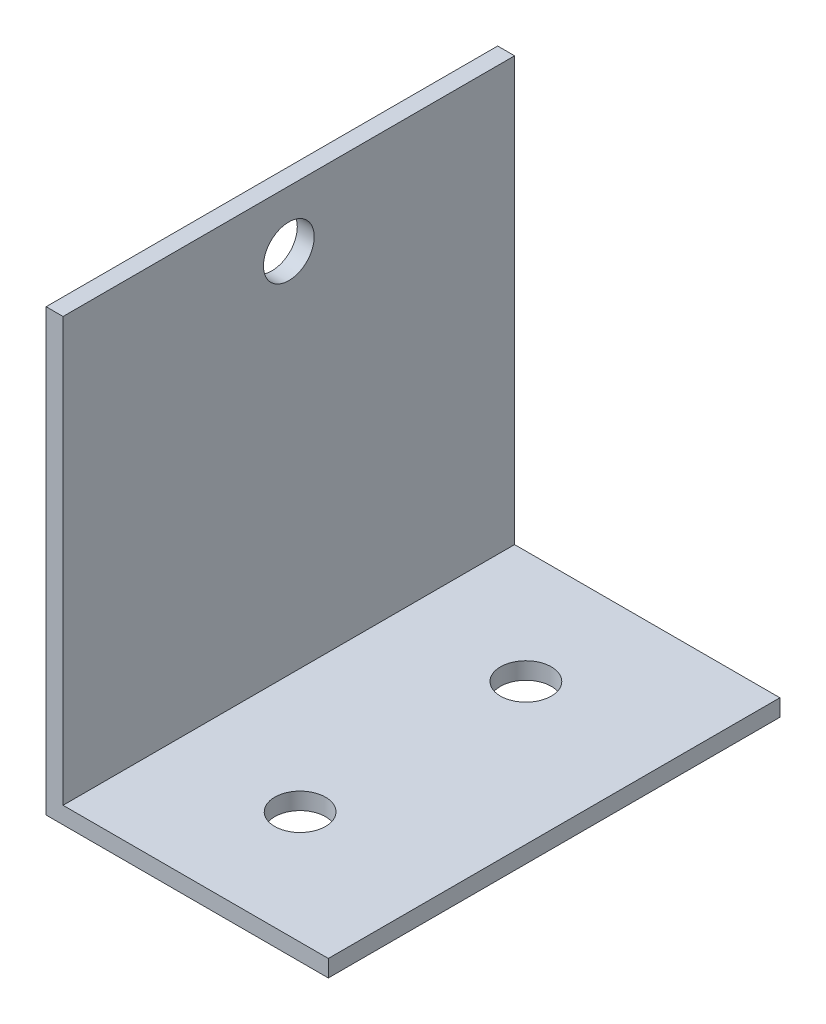
from build123d import *

# Parameters (mm, degrees)
EXTRU_MINCE1_DEPTH = 40
D_GAGEMENT_M41_D   = 4.5
D_GAGEMENT_M42_D   = 4.5


with BuildPart() as part:
    # Esquisse1 → Extru.-Mince1 (new body)
    with BuildSketch(Plane.XY):
        Polygon((0, 39), (0, 0), (25, 0), (25, 1.5), (1.5, 1.5), (1.5, 39), align=None)
    extrude(amount=-EXTRU_MINCE1_DEPTH)

    # Dégagement M41 (through all)
    with Locations(Plane(origin=(0, 1.5, 0), x_dir=(-1, 0, 0), z_dir=(0, 1, 0))):
        with Locations((-12.5, -10), (-12.5, -30)):
            Hole(D_GAGEMENT_M41_D / 2)

    # Dégagement M42 (through all)
    with Locations(Plane(origin=(1.5, 0, 0), x_dir=(0, 0, -1), z_dir=(1, 0, 0))):
        with Locations((20, 34)):
            Hole(D_GAGEMENT_M42_D / 2)


solid = part.part
